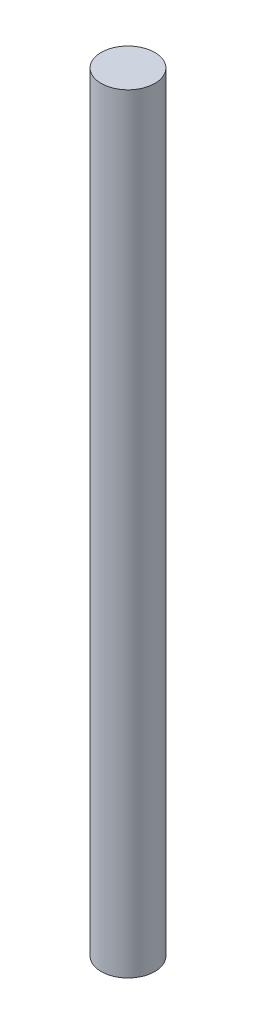
from build123d import *

# Parameters (mm, degrees)
SKETCH1_R           = 0.75
BOSS_EXTRUDE1_DEPTH = 21.5


with BuildPart() as part:
    # Sketch1 → Boss-Extrude1 (new body)
    with BuildSketch(Plane(origin=(0, 0, 0), x_dir=(1, 0, 0), z_dir=(0, 1, 0))):
        Circle(SKETCH1_R)
    extrude(amount=BOSS_EXTRUDE1_DEPTH)


solid = part.part
